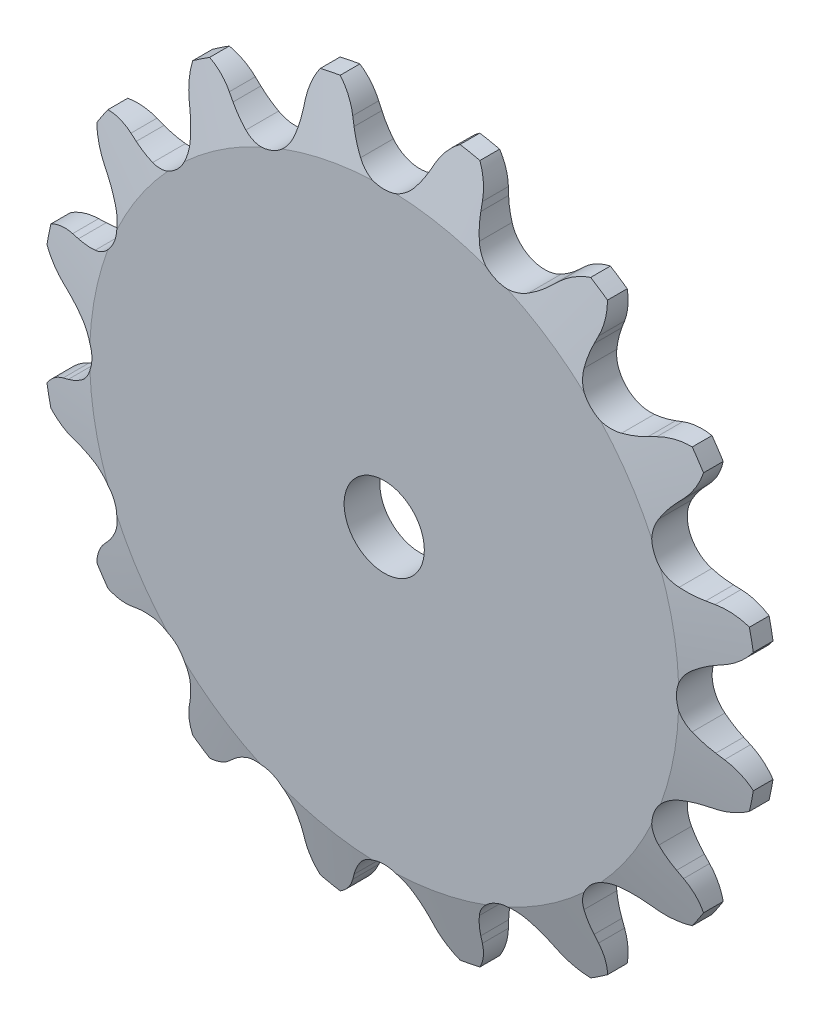
from build123d import *

# Parameters (mm, degrees)
TOOTH_CUT_NUMBER_OF_TEETH_16_DEPTH = 26.306064487
TOOTH_PATTERN_16_16_COUNT          = 16
CUT_EXTRUDE1_DEPTH                 = 25.950439678
CUT_EXTRUDE1_DEPTH_BACK            = 25.950439678
SKETCH4_R                          = 2
SKETCH6_R                          = 27.175843836
CUT_EXTRUDE2_DEPTH                 = 1.016


with BuildPart() as part:
    # Sprocket-BaseSketch → 25 _04C_ ANSI _ISO_ Chain Number_ 1.281i (revolve)
    with BuildSketch(Plane(origin=(0, 0, 0), x_dir=(0, 0, -1), z_dir=(1, 0, 0))):
        Polygon((1.397, 0), (1.397, 14.691802887), (0.60325, 17.866802887), (-0.60325, 17.866802887), (-1.397, 14.691802887), (-1.397, 0), align=None)
    revolve(axis=Axis((0, 0, -5.588), (0, 0, 1)))

    # Tooth-Sketch → Tooth-Cut_ Number of teeth_ 16 (cut, symmetric)
    with BuildSketch(Plane.XY):
        with BuildLine():
            Line((1.895951627, 16.145861918), (2.051408678, 16.490963774))
            ThreePointArc((2.051408678, 16.490963774), (3.056004647, 17.659429879), (4.533974194, 18.095471295))
            ThreePointArc((4.533974194, 18.095471295), (0, 18.654838605), (-4.533974194, 18.095471295))
            ThreePointArc((-4.533974194, 18.095471295), (-3.056004647, 17.659429879), (-2.051408678, 16.490963774))
            Line((-2.051408678, 16.490963774), (-1.895951627, 16.145861918))
            ThreePointArc((-1.895951627, 16.145861918), (-1.639424454, 15.660854777), (-1.323740827, 15.212098758))
            ThreePointArc((-1.323740827, 15.212098758), (0, 14.577158093), (1.323740827, 15.212098758))
            ThreePointArc((1.323740827, 15.212098758), (1.639424454, 15.660854777), (1.895951627, 16.145861918))
        make_face()
    tooth_cut_number_of_teeth_16 = extrude(amount=TOOTH_CUT_NUMBER_OF_TEETH_16_DEPTH, both=True, mode=Mode.SUBTRACT)

    # Tooth Pattern_ 16 _ 16: Tooth-Cut_ Number of teeth_ 16 ×16 about axis
    tooth_pattern_16_16_axis = Axis((0, 0, -88.99), (0, 0, 1))
    for i in range(1, TOOTH_PATTERN_16_16_COUNT):
        add(tooth_cut_number_of_teeth_16.rotate(tooth_pattern_16_16_axis, i * 360 / TOOTH_PATTERN_16_16_COUNT), mode=Mode.SUBTRACT)

    # Sketch4 → Cut-Extrude1 (cut, two sides: drawn at the far end of the back side and taken through both)
    with BuildSketch(Plane.XY.offset(-CUT_EXTRUDE1_DEPTH_BACK)):
        Circle(SKETCH4_R)
    extrude(amount=CUT_EXTRUDE1_DEPTH + CUT_EXTRUDE1_DEPTH_BACK, mode=Mode.SUBTRACT)

    # Sketch6 → Cut-Extrude2 (cut)
    with BuildSketch(Plane(origin=(0, 0, -1.397), x_dir=(-1, 0, 0), z_dir=(0, 0, -1))):
        Circle(SKETCH6_R)
    extrude(amount=-CUT_EXTRUDE2_DEPTH, mode=Mode.SUBTRACT)


solid = part.part
